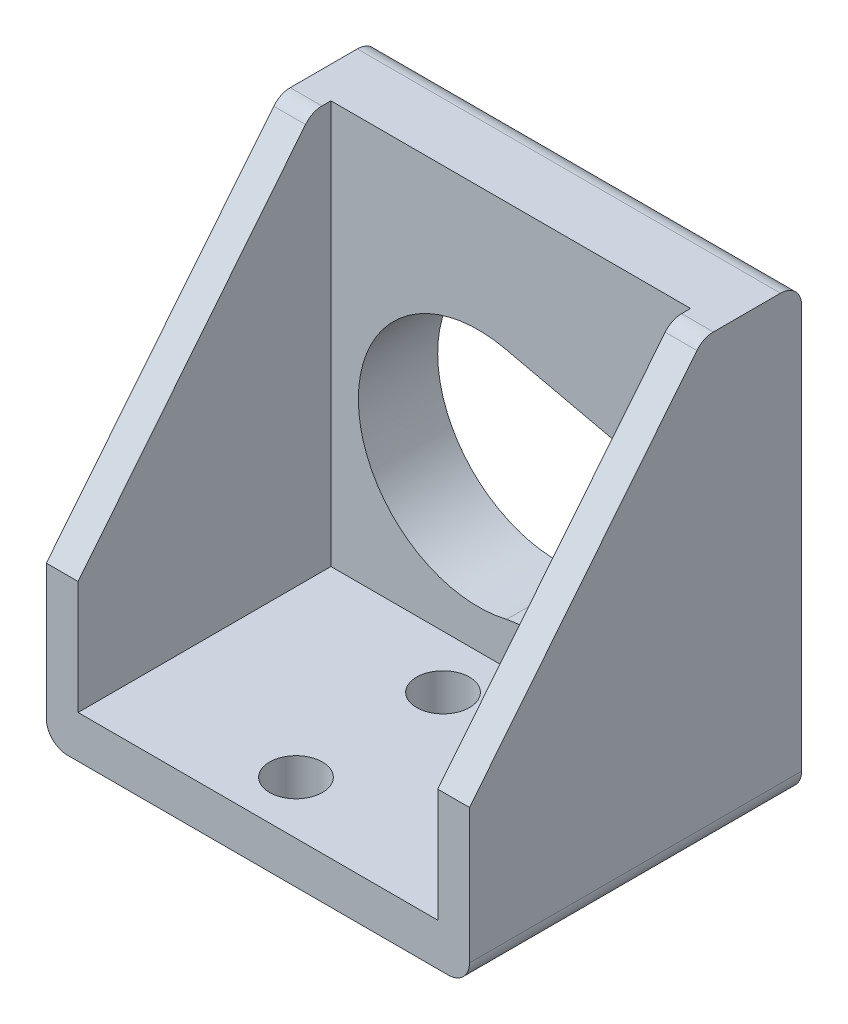
from build123d import *

# Parameters (mm, degrees)
SKETCH1_W           = 50.8
SKETCH1_H           = 39.878
BOSS_EXTRUDE1_DEPTH = 53.499926347
SKETCH3_W           = 43.18
SKETCH3_H           = 50.8
CUT_EXTRUDE1_DEPTH  = 30.353
CUT_EXTRUDE2_DEPTH  = 51.8
FILLET3_R           = 2.54
FILLET4_R           = 2.54
FILLET5_R           = 2.54
SKETCH5_R           = 3.175
CUT_EXTRUDE3_DEPTH  = 6.08
CUT_EXTRUDE4_DEPTH  = 25.4


with BuildPart() as part:
    # Sketch1 → Boss-Extrude1 (new body)
    with BuildSketch(Plane(origin=(0, 0, 0), x_dir=(1, 0, 0), z_dir=(0, 1, 0))):
        with Locations((25.4, 19.939)):
            Rectangle(SKETCH1_W, SKETCH1_H)
    extrude(amount=BOSS_EXTRUDE1_DEPTH)

    # Sketch3 → Cut-Extrude1 (cut)
    with BuildSketch(Plane.XY):
        with Locations((25.4, 30.48)):
            Rectangle(SKETCH3_W, SKETCH3_H)
    extrude(amount=-CUT_EXTRUDE1_DEPTH, mode=Mode.SUBTRACT)

    # Sketch4 → Cut-Extrude2 (cut, through all)
    with BuildSketch(Plane.ZY):
        Polygon((0, 18.701926347), (-28.067, 53.499926347), (0, 53.499926347), align=None)
    extrude(amount=-CUT_EXTRUDE2_DEPTH, mode=Mode.SUBTRACT)

    # Fillet3
    fillet3_edges = [part.edges().sort_by_distance(p)[0] for p in [
        (25.4, 53.499926347, -39.878),
    ]]
    fillet(fillet3_edges, radius=FILLET3_R)

    # Fillet4
    fillet4_edges = [part.edges().sort_by_distance(p)[0] for p in [
        (48.895, 53.499926347, -28.067),
        (1.905, 53.499926347, -28.067),
    ]]
    fillet(fillet4_edges, radius=FILLET4_R)

    # Fillet5
    fillet5_edges = [part.edges().sort_by_distance(p)[0] for p in [
        (50.8, 0, -19.939),
        (0, 0, -19.939),
    ]]
    fillet(fillet5_edges, radius=FILLET5_R)

    # Sketch5 → Cut-Extrude3 (cut, through all)
    with BuildSketch(Plane(origin=(0, 5.08, 0), x_dir=(1, 0, 0), z_dir=(0, 1, 0))):
        with Locations((23.622, 6.35)):
            Circle(SKETCH5_R)
        with Locations((23.622, 24.003)):
            Circle(SKETCH5_R)
    extrude(amount=-CUT_EXTRUDE3_DEPTH, mode=Mode.SUBTRACT)

    # Sketch13 → Cut-Extrude4 (cut)
    with BuildSketch(Plane.XY.offset(-30.353)):
        with BuildLine():
            Line((45.078473315, 33.54111133), (45.078473315, 13.162010507))
            Line((45.078473315, 13.162010507), (24.90196768, 10.132947276))
            ThreePointArc((24.90196768, 10.132947276), (7.104992388, 24.03759453), (24.712163172, 38.181818856))
            Line((24.712163172, 38.181818856), (45.078473315, 33.54111133))
        make_face()
    extrude(amount=-CUT_EXTRUDE4_DEPTH, mode=Mode.SUBTRACT)


solid = part.part
